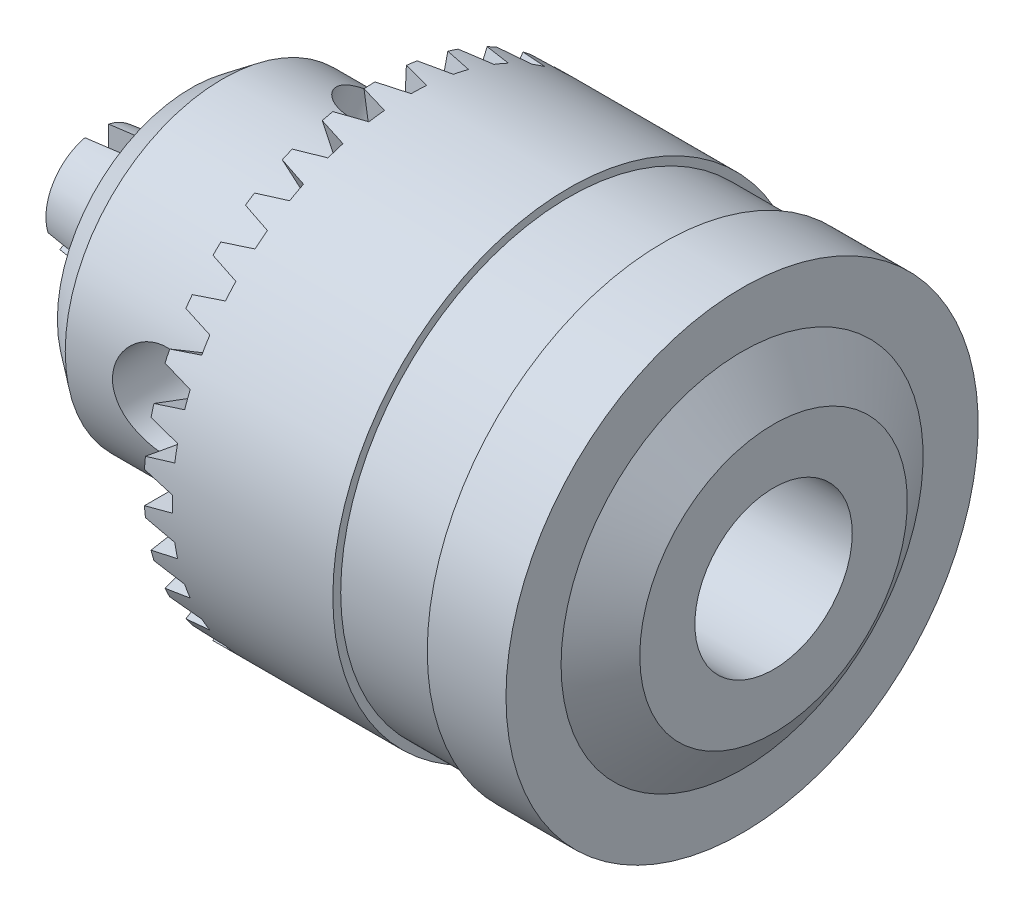
from build123d import *

# Parameters (mm, degrees)
SKETCH2_R           = 5
CUT_EXTRUDE1_DEPTH  = 16.7
CUT_EXTRUDE2_REACH  = 39
SKETCH3_R           = 4
SKETCH4_R           = 3
CUT_EXTRUDE3_DEPTH  = 4.65
CIRPATTERN1_COUNT   = 3
CUT_EXTRUDE4_DEPTH  = 5
CIRPATTERN2_COUNT   = 35
BOSS_EXTRUDE1_DEPTH = 6
CUT_EXTRUDE5_REACH  = 39
SCALE1_SCALE        = 2.5


with BuildPart() as part:
    # Sketch1 → Revolve1 (revolve)
    with BuildSketch(Plane.XY):
        Polygon((-18.5, 0), (18.5, 0), (18.5, 8.5), (16.5, 11.5), (16.5, 15), (11.5, 15), (11.5, 14.5), (5.5, 14.5), (5.5, 15), (-6.5, 15), (-6.5, 10), (-16.5, 10), (-18.5, 8.5), align=None)
    revolve(axis=Axis((-18.5, 0, 0), (1, 0, 0)))

    # Sketch2 → Cut-Extrude1 (cut)
    with BuildSketch(Plane(origin=(18.5, 0, 0), x_dir=(0, 0, -1), z_dir=(1, 0, 0))):
        Circle(SKETCH2_R)
    extrude(amount=-CUT_EXTRUDE1_DEPTH, mode=Mode.SUBTRACT)

    # Sketch3 → Cut-Extrude2 (cut, up to next)
    with BuildSketch(Plane.ZY.offset(18.5), mode=Mode.PRIVATE) as cut_extrude2_sk1:
        Circle(SKETCH3_R)
    cut_extrude2_tool1 = extrude(cut_extrude2_sk1.sketch, amount=-CUT_EXTRUDE2_REACH, mode=Mode.PRIVATE) & part.part
    add(cut_extrude2_tool1.solids().sort_by_distance((-18.5, 0, 0))[0], mode=Mode.SUBTRACT)

    # Sketch4 → Cut-Extrude3 (cut)
    with BuildSketch(Plane.XY.offset(10)):
        with Locations((-10.5, 0)):
            Circle(SKETCH4_R)
    cut_extrude3 = extrude(amount=-CUT_EXTRUDE3_DEPTH, mode=Mode.SUBTRACT)

    # CirPattern1: Cut-Extrude3 ×3 about axis
    cirpattern1_axis = Axis((0, 0, 0), (1, 0, 0))
    for i in range(1, CIRPATTERN1_COUNT):
        add(cut_extrude3.rotate(cirpattern1_axis, i * 360 / CIRPATTERN1_COUNT), mode=Mode.SUBTRACT)

    # Sketch5 → Cut-Extrude4 (cut)
    with BuildSketch(Plane.XY.offset(10)):
        Polygon((-6.5, 1), (-4.7, 0.5), (-4.7, -0.5), (-6.5, -1), align=None)
    cut_extrude4 = extrude(amount=CUT_EXTRUDE4_DEPTH, mode=Mode.SUBTRACT)

    # CirPattern2: Cut-Extrude4 ×35 about axis
    cirpattern2_axis = Axis((0, 0, 0), (1, 0, 0))
    for i in range(1, CIRPATTERN2_COUNT):
        add(cut_extrude4.rotate(cirpattern2_axis, i * 360 / CIRPATTERN2_COUNT), mode=Mode.SUBTRACT)

    # Sketch6 → Boss-Extrude1 (add)
    with BuildSketch(Plane.ZY.offset(18.5)):
        with BuildLine():
            Line((0.75, 3.977400374), (0.75, 0.433012702))
            Line((0.75, 0.433012702), (3.819529765, -1.339181134))
            ThreePointArc((3.819529765, -1.339181134), (3.505233274, 2.023747374), (0.75, 3.977400374))
        make_face()
        with BuildLine():
            Line((-0.75, 3.977400374), (-0.75, 0.433012702))
            Line((-0.75, 0.433012702), (-3.819529765, -1.339181134))
            ThreePointArc((-3.819529765, -1.339181134), (-3.505233274, 2.023747374), (-0.75, 3.977400374))
        make_face()
        with BuildLine():
            Line((0, -0.866025404), (-3.069529765, -2.63821924))
            ThreePointArc((-3.069529765, -2.63821924), (0, -4.047494748), (3.069529765, -2.63821924))
            Line((3.069529765, -2.63821924), (0, -0.866025404))
        make_face()
    extrude(amount=BOSS_EXTRUDE1_DEPTH)

    # Sketch12 → Cut-Revolve3 (revolve, cut)
    with BuildSketch(Plane(origin=(0, 0, 0), x_dir=(1, 0, 0), z_dir=(0, 0.866025404, -0.5))):
        Polygon((-18.5, 4.377400374), (-24.5, 4.377400374), (-24.5, 3.227400374), (-18.5, 3.977400374), align=None)
    revolve(axis=Axis((-10.374418026, 0, 0), (-1, 0, 0)), mode=Mode.SUBTRACT)

    # Sketch14 → Revolve2 (revolve)
    with BuildSketch(Plane(origin=(0, 0, 0), x_dir=(1, 0, 0), z_dir=(0, 0.866025404, -0.5))):
        Polygon((-18.5, 0.433012702), (-13.45473427, 4), (-18.5, 4), align=None)
    revolve(axis=Axis((-10.5, 0, 0), (-1, 0, 0)))

    # Sketch15 → Cut-Extrude5 (cut, up to next)
    with BuildSketch(Plane.ZY.offset(18.5), mode=Mode.PRIVATE) as cut_extrude5_sk1:
        Polygon((0.75, 3.906048353), (0.75, 0.433012702), (3.757737102, -1.303505124), (3.007737102, -2.602543229), (0, -0.866025404), (-3.007737102, -2.602543229), (-3.757737102, -1.303505124), (-0.75, 0.433012702), (-0.75, 3.906048353), align=None)
    cut_extrude5_tool1 = extrude(cut_extrude5_sk1.sketch, amount=-CUT_EXTRUDE5_REACH, mode=Mode.PRIVATE) & part.part
    add(cut_extrude5_tool1.solids().sort_by_distance((-18.5, 0, 0))[0], mode=Mode.SUBTRACT)


with BuildPart() as part_1:
    # Scale1: scaled about (2.364071987, 2.68e-07, -1.4604e-05)
    add(part.part.scale(SCALE1_SCALE).moved(Location((-3.54610798, -4.02e-07, 2.1906e-05))))


solid = part_1.part
